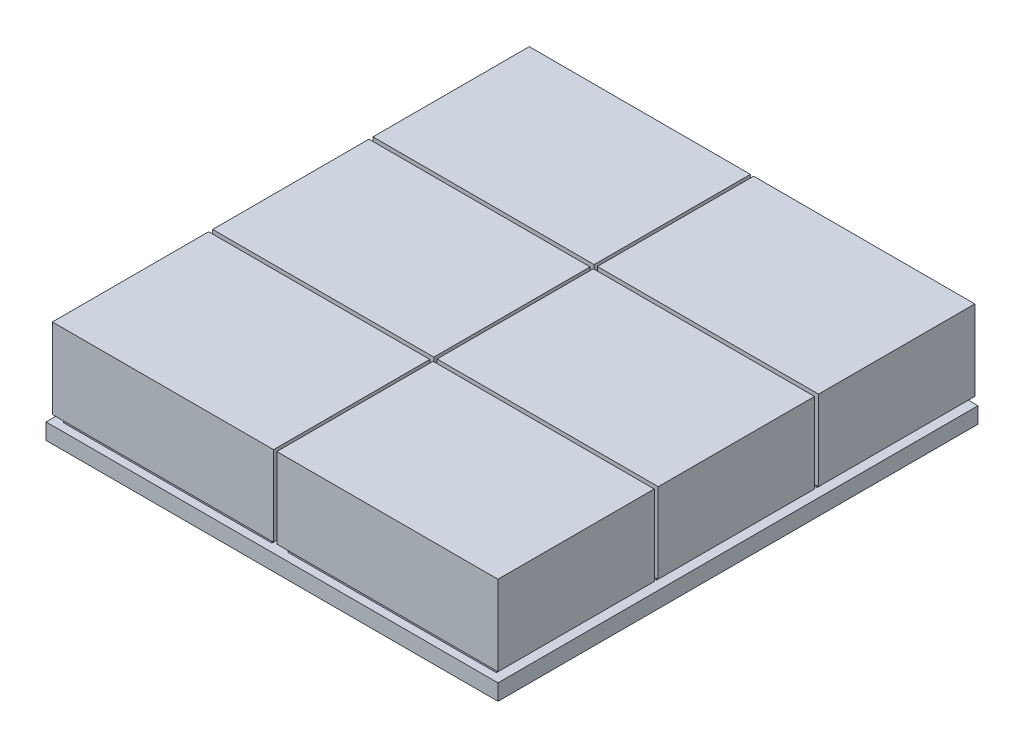
from build123d import *

# Parameters (mm, degrees)
SKETCH1_W                 = 71
SKETCH1_H                 = 250
BOSS_EXTRUDE1_DEPTH       = 5
SKETCH2_W                 = 65
SKETCH2_H                 = 45
BOSS_EXTRUDE3_DEPTH       = 2
LPATTERN1_COUNT           = 3
LPATTERN1_PITCH           = 50
SKETCH3_W                 = 69
SKETCH3_H                 = 48.754858224
BOSS_EXTRUDE8_DEPTH       = 25
LPATTERN5_COUNT           = 3
LPATTERN5_PITCH           = 50
LPATTERN6_COUNT           = 2
LPATTERN6_PITCH           = 70
LPATTERN6_COPY_1_SKETCH_W = 65
LPATTERN6_COPY_1_SKETCH_H = 45
LPATTERN6_COPY_1_DEPTH    = 2
LPATTERN6_COPY_2_SKETCH_W = 65
LPATTERN6_COPY_2_SKETCH_H = 45
LPATTERN6_COPY_2_DEPTH    = 2
LPATTERN6_COPY_3_SKETCH_W = 69
LPATTERN6_COPY_3_SKETCH_H = 48.754858224
LPATTERN6_COPY_3_DEPTH    = 25
LPATTERN6_COPY_4_SKETCH_W = 69
LPATTERN6_COPY_4_SKETCH_H = 48.754858224
LPATTERN6_COPY_4_DEPTH    = 25
SKETCH6_W                 = 141
SKETCH6_H                 = 100.266772644
CUT_EXTRUDE1_DEPTH        = 10


with BuildPart() as part:
    # Sketch1 → Boss-Extrude1 (new body)
    with BuildSketch(Plane(origin=(0, 0, 0), x_dir=(1, 0, 0), z_dir=(0, 1, 0))):
        Rectangle(SKETCH1_W, SKETCH1_H)
    boss_extrude1 = extrude(amount=BOSS_EXTRUDE1_DEPTH)

    # Sketch2 → Boss-Extrude3 (add)
    with BuildSketch(Plane(origin=(0, 5, 0), x_dir=(1, 0, 0), z_dir=(0, 1, 0))):
        with Locations((0, -100)):
            Rectangle(SKETCH2_W, SKETCH2_H)
    boss_extrude3 = extrude(amount=BOSS_EXTRUDE3_DEPTH)

    # LPattern1: Boss-Extrude3 ×3
    with Locations(*[(0, 0, -i * LPATTERN1_PITCH) for i in range(1, LPATTERN1_COUNT)]):
        add(boss_extrude3)

    # Sketch3 → Boss-Extrude8 (add)
    with BuildSketch(Plane(origin=(0, 7, 0), x_dir=(1, 0, 0), z_dir=(0, 1, 0))):
        with Locations((0, -99.635002086)):
            Rectangle(SKETCH3_W, SKETCH3_H)
    boss_extrude8 = extrude(amount=BOSS_EXTRUDE8_DEPTH)

    # LPattern5: Boss-Extrude8 ×3
    with Locations(*[(0, 0, -i * LPATTERN5_PITCH) for i in range(1, LPATTERN5_COUNT)]):
        add(boss_extrude8)

    # LPattern6: Boss-Extrude1, Boss-Extrude3, Boss-Extrude8 ×2
    with Locations(*[(i * LPATTERN6_PITCH, 0, 0) for i in range(1, LPATTERN6_COUNT)]):
        add(boss_extrude1)
        add(boss_extrude3)
        add(boss_extrude8)

    # LPattern6 copy 1 sketch → LPattern6 copy 1 (add)
    with BuildSketch(Plane(origin=(70, 5, -50), x_dir=(1, 0, 0), z_dir=(0, 1, 0))):
        with Locations((0, -100)):
            Rectangle(LPATTERN6_COPY_1_SKETCH_W, LPATTERN6_COPY_1_SKETCH_H)
    extrude(amount=LPATTERN6_COPY_1_DEPTH)

    # LPattern6 copy 2 sketch → LPattern6 copy 2 (add)
    with BuildSketch(Plane(origin=(70, 5, -100), x_dir=(1, 0, 0), z_dir=(0, 1, 0))):
        with Locations((0, -100)):
            Rectangle(LPATTERN6_COPY_2_SKETCH_W, LPATTERN6_COPY_2_SKETCH_H)
    extrude(amount=LPATTERN6_COPY_2_DEPTH)

    # LPattern6 copy 3 sketch → LPattern6 copy 3 (add)
    with BuildSketch(Plane(origin=(70, 7, -50), x_dir=(1, 0, 0), z_dir=(0, 1, 0))):
        with Locations((0, -99.635002086)):
            Rectangle(LPATTERN6_COPY_3_SKETCH_W, LPATTERN6_COPY_3_SKETCH_H)
    extrude(amount=LPATTERN6_COPY_3_DEPTH)

    # LPattern6 copy 4 sketch → LPattern6 copy 4 (add)
    with BuildSketch(Plane(origin=(70, 7, -100), x_dir=(1, 0, 0), z_dir=(0, 1, 0))):
        with Locations((0, -99.635002086)):
            Rectangle(LPATTERN6_COPY_4_SKETCH_W, LPATTERN6_COPY_4_SKETCH_H)
    extrude(amount=LPATTERN6_COPY_4_DEPTH)

    # Sketch6 → Cut-Extrude1 (cut)
    with BuildSketch(Plane(origin=(0, 5, 0), x_dir=(1, 0, 0), z_dir=(0, 1, 0))):
        with Locations((35, 74.866613678)):
            Rectangle(SKETCH6_W, SKETCH6_H)
    extrude(amount=-CUT_EXTRUDE1_DEPTH, mode=Mode.SUBTRACT)


solid = part.part
